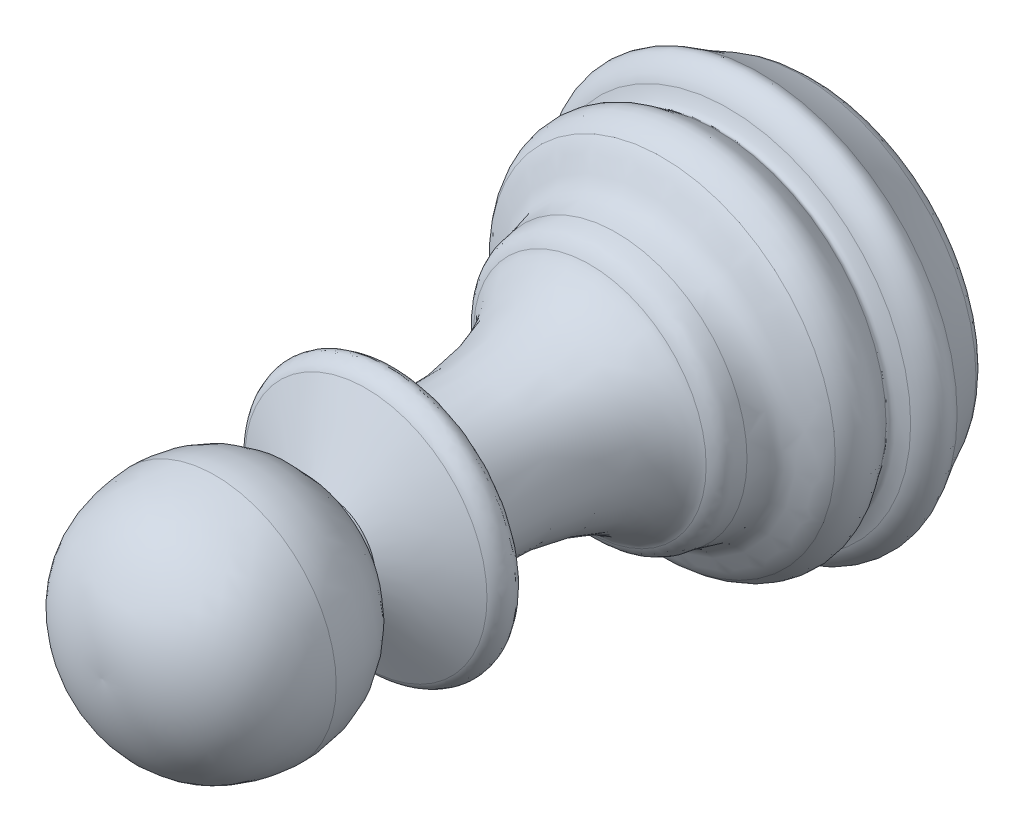
from build123d import *

# Parameters (mm, degrees)
FILLET2_R = 15


with BuildPart() as part:
    # Sketch1 → Revolve2 (revolve)
    with BuildSketch(Plane(origin=(0, 0, 0), x_dir=(0, -1, 0), z_dir=(-1, 0, 0))):
        with BuildLine():
            Line((0, 26.625071466), (0, 0))
            Line((0, 0), (5.543805409, 0))
            add(Edge.make_bspline(
                [(6.319793296, 1.525847677), (6.889302205, 0.686287118), (5.543805409, 0)],
                knots=[0, 0, 0, 1, 1, 1], degree=2))
            add(Edge.make_bspline(
                [(7.085307754, 2.055592338), (6.864738604, 1.829988787), (6.609567118, 1.653407233), (6.319793296, 1.525847677)],
                knots=[0, 0, 0, 0, 1, 1, 1, 1], degree=3))
            add(Edge.make_bspline(
                [(6.741362661, 3.478452892), (6.970710589, 3.391049286), (7.40122549, 3.03910509), (7.53941056, 2.520059856), (7.085307754, 2.055592338)],
                knots=[0, 0, 0, 0, 0.372722308, 1, 1, 1, 1], degree=3))
            add(Edge.make_bspline(
                [(6.247749325, 3.897860565), (6.218723376, 3.855258339), (6.183941334, 3.717754673), (6.445100579, 3.573341428), (6.690034137, 3.498013993), (6.741362661, 3.478452892)],
                knots=[0, 0, 0, 0, 0.162366513, 0.584346053, 1, 1, 1, 1], degree=3))
            add(Edge.make_bspline(
                [(6.402401794, 5.930190735), (6.784177677, 5.531343902), (6.951661459, 4.728187202), (6.426334589, 4.159975336), (6.247749325, 3.897860565)],
                knots=[0, 0, 0, 0, 0.588501572, 1, 1, 1, 1], degree=3))
            add(Edge.make_bspline(
                [(4.833967561, 7.625249343), (4.874718363, 7.30367232), (5.109048802, 6.449189117), (6.007021611, 6.343250178), (6.402401794, 5.930190735)],
                knots=[0, 0, 0, 0, 0.377644998, 1, 1, 1, 1], degree=3))
            add(Edge.make_bspline(
                [(4.301931531, 8.604902513), (4.459652634, 8.524803103), (4.778738537, 8.275930853), (4.799900285, 7.894084624), (4.833967561, 7.625249343)],
                knots=[0, 0, 0, 0, 0.408405695, 1, 1, 1, 1], degree=3))
            add(Edge.make_bspline(
                [(2.735852942, 15.689695119), (2.13635684, 11.136275765), (3.716131859, 8.902403651), (4.301931531, 8.604902513)],
                knots=[0, 0, 0, 0, 1, 1, 1, 1], degree=3))
            Line((2.735852942, 15.689695119), (4.146774256, 15.689695119))
            add(Edge.make_bspline(
                [(4.479001376, 16.888442397), (4.679498126, 16.786031007), (5.067202986, 16.164049956), (4.493493746, 15.689695119), (4.146774256, 15.689695119)],
                knots=[0, 0, 0, 0, 0.447467442, 1, 1, 1, 1], degree=3))
            Line((4.479001376, 16.888442397), (1.748997287, 18.282896499))
            Line((1.748997287, 18.282896499), (1.748997287, 18.519100682))
            add(Edge.make_bspline(
                [(4.479001376, 22.465552786), (4.493335744, 19.724714624), (1.748997287, 18.519100682)],
                knots=[0, 0, 0, 1, 1, 1], degree=2))
            add(Edge.make_bspline(
                [(0, 26.625071466), (1.261982799, 26.720448123), (3.78083459, 25.70244409), (4.410562491, 23.567274656), (4.479001376, 22.465552786)],
                knots=[0, 0, 0, 0, 0.57860408, 1, 1, 1, 1], degree=3))
        make_face()
    revolve(axis=Axis((0, 0, 26.625071466), (0, 0, -1)))

    # Fillet2
    fillet2_edges = [part.edges().sort_by_distance(p)[0] for p in [
        (0, 6.319793296, 1.525847677),
    ]]
    fillet(fillet2_edges, radius=FILLET2_R)


solid = part.part
